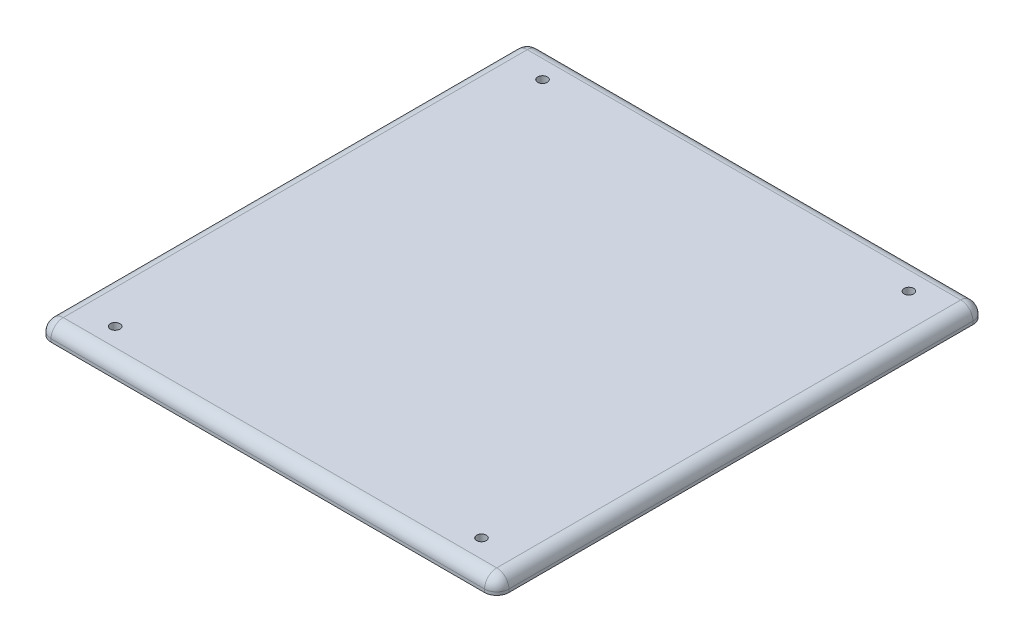
from build123d import *

# Parameters (mm, degrees)
SKETCH1_W           = 95.25
SKETCH1_H           = 101.6
BOSS_EXTRUDE1_DEPTH = 3.175
SKETCH5_R           = 0.99949
CUT_EXTRUDE3_DEPTH  = 3.175
CIRPATTERN3_COUNT   = 2
FILLET1_R           = 2.54
CHAMFER1_SIZE       = 1.27


with BuildPart() as part:
    # Sketch1 → Boss-Extrude1 (new body)
    with BuildSketch(Plane(origin=(0, 0, 0), x_dir=(1, 0, 0), z_dir=(0, 1, 0))):
        Rectangle(SKETCH1_W, SKETCH1_H)
    extrude(amount=BOSS_EXTRUDE1_DEPTH)

    # Sketch5 → Cut-Extrude3 (cut)
    with BuildSketch(Plane(origin=(0, 3.175, 0), x_dir=(1, 0, 0), z_dir=(0, 1, 0))):
        with Locations((-38.1, -44.45)):
            Circle(SKETCH5_R)
        with Locations((38.1, -44.45)):
            Circle(SKETCH5_R)
    cut_extrude3 = extrude(amount=-CUT_EXTRUDE3_DEPTH, mode=Mode.SUBTRACT)

    # CirPattern3: Cut-Extrude3 ×2 about axis
    cirpattern3_axis = Axis((0, 3.33375, 0), (0, -1, 0))
    for i in range(1, CIRPATTERN3_COUNT):
        add(cut_extrude3.rotate(cirpattern3_axis, i * 360 / CIRPATTERN3_COUNT), mode=Mode.SUBTRACT)

    # Fillet1
    fillet1_edges = [part.edges().sort_by_distance(p)[0] for p in [
        (47.625, 3.175, 0),
        (0, 3.175, 50.8),
        (-47.625, 3.175, 0),
        (0, 3.175, -50.8),
        (-47.625, 1.5875, -50.8),
        (47.625, 1.5875, -50.8),
        (47.625, 1.5875, 50.8),
        (-47.625, 1.5875, 50.8),
    ]]
    fillet(fillet1_edges, radius=FILLET1_R)

    # Chamfer1
    chamfer1_edges = [part.edges().sort_by_distance(p)[0] for p in [
        (39.09949, 0, -44.45),
        (-37.10051, 0, -44.45),
        (-39.09949, 0, 44.45),
        (37.10051, 0, 44.45),
    ]]
    chamfer(chamfer1_edges, length=CHAMFER1_SIZE)


solid = part.part
